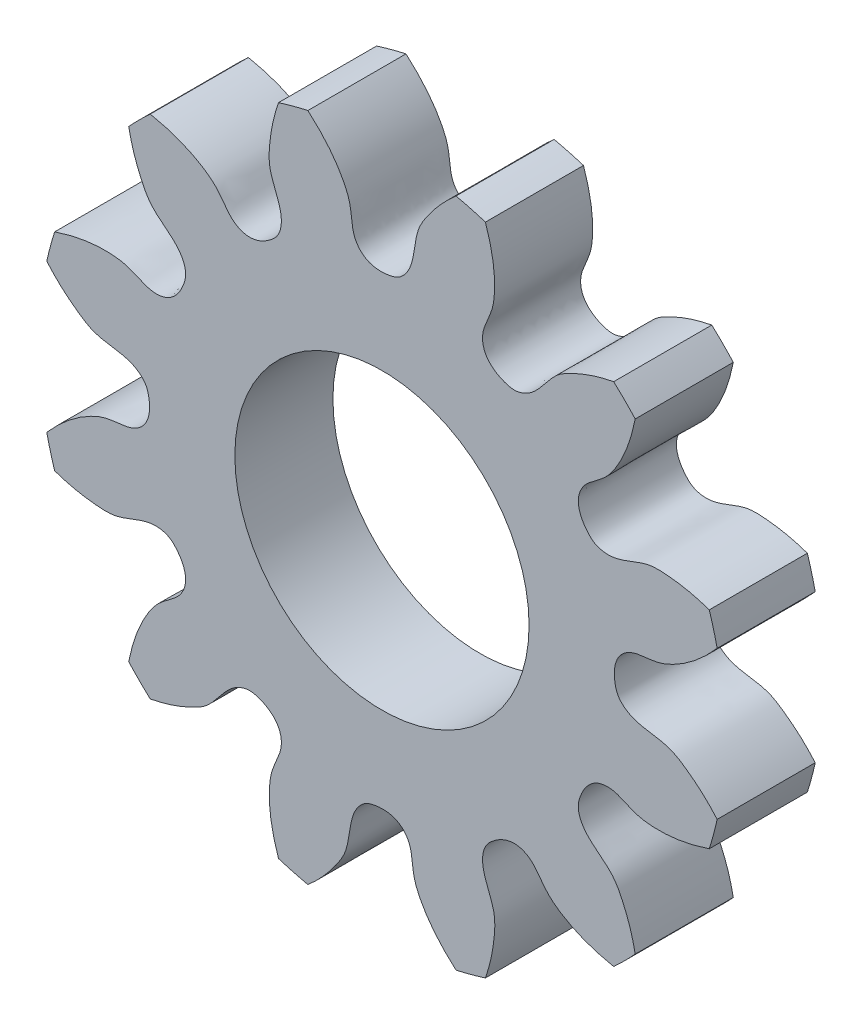
from build123d import *

# Parameters (mm, degrees)
SKETCHREVOLVEN12_ENCODER_W       = 2
SKETCHREVOLVEN12_ENCODER_H       = 6.999999895
TOOTHEXTRUDECUTN12_ENCODER_DEPTH = 1
PATTERNN12_ENCODER_COUNT         = 12
BOREREVOLVESKETCH_W              = 2
BOREREVOLVESKETCH_H              = 3


with BuildPart() as part:
    # SketchRevolveN12_encoder → N12_encoder (revolve)
    with BuildSketch(Plane(origin=(0, 0, 0), x_dir=(0, 0, -1), z_dir=(1, 0, 0))):
        with Locations((0, 3.499999948)):
            Rectangle(SKETCHREVOLVEN12_ENCODER_W, SKETCHREVOLVEN12_ENCODER_H)
    revolve(axis=Axis((0, 0, 0), (0, 0, -1)))

    # SketchToothN12_encoder → ToothExtrudeCutN12_encoder (cut, symmetric)
    with BuildSketch(Plane.XY):
        with BuildLine():
            ThreePointArc((6.875836171, 1.557361696), (7.049999894, 0), (6.875836171, -1.557361696))
            add(Edge.make_bspline(
                [(6.875836171, -1.557361696), (6.752425567, -1.412076109), (6.539013852, -1.190383256), (6.205619219, -0.934160362), (5.829296464, -0.684809415), (5.422152583, -0.672168213), (5.090671306, -0.574624686), (4.924024099, -0.472497044), (4.793967936, -0.329630493), (4.734899415, -0.097560899), (4.731516323, 0.15182102), (4.834796075, 0.397234062), (5.121910645, 0.633214362), (5.55656172, 0.602772942), (6.225038066, 0.894731292), (6.618730744, 1.254683387), (6.875836171, 1.557361696)],
                knots=[0, 0, 0, 0, 0.101357264, 0.162593944, 0.224534496, 0.336345061, 0.376288102, 0.407095315, 0.439690928, 0.476365469, 0.533171075, 0.568791946, 0.616016045, 0.721304958, 0.788839032, 1, 1, 1, 1], degree=3))
        make_face()
    toothextrudecutn12_encoder = extrude(amount=TOOTHEXTRUDECUTN12_ENCODER_DEPTH, both=True, mode=Mode.SUBTRACT)

    # PatternN12_encoder: ToothExtrudeCutN12_encoder ×12 about axis
    patternn12_encoder_axis = Axis((0, 0, 50), (0, 0, -1))
    for i in range(1, PATTERNN12_ENCODER_COUNT):
        add(toothextrudecutn12_encoder.rotate(patternn12_encoder_axis, i * 360 / PATTERNN12_ENCODER_COUNT), mode=Mode.SUBTRACT)

    # BoreRevolveSketch → BoreRevolveCut (revolve, cut)
    with BuildSketch(Plane(origin=(0, 0, 0), x_dir=(0, 0, -1), z_dir=(1, 0, 0))):
        with Locations((0, 1.5)):
            Rectangle(BOREREVOLVESKETCH_W, BOREREVOLVESKETCH_H)
    revolve(axis=Axis((0, 0, 0), (0, 0, -1)), mode=Mode.SUBTRACT)


solid = part.part
